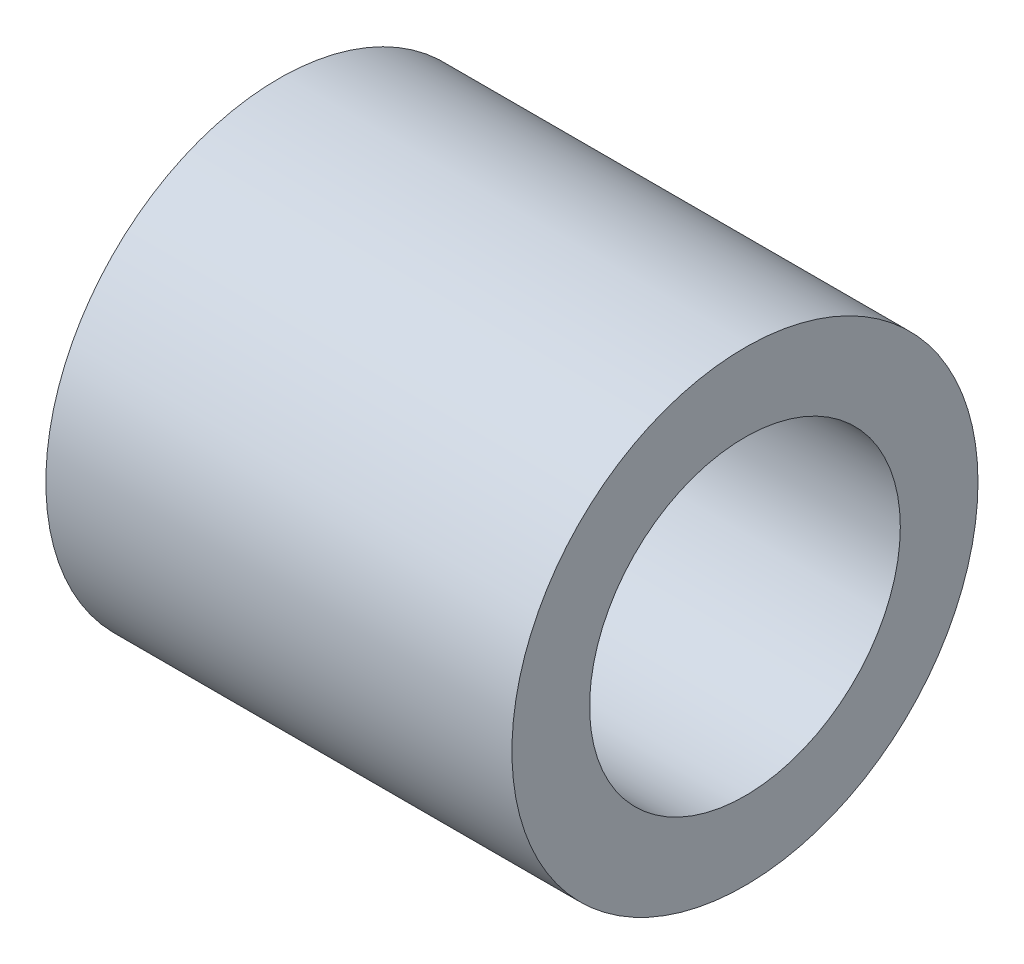
from build123d import *

# Parameters (mm, degrees)
SKETCH_1_R      = 9
SKETCH_1_R_2    = 6
EXTRUDE_1_DEPTH = 18


with BuildPart() as part:
    # 草图1 → 凸台-拉伸1 (new body)
    with BuildSketch(Plane(origin=(0, 0, 0), x_dir=(0, 0, -1), z_dir=(1, 0, 0))):
        Circle(SKETCH_1_R)
        Circle(SKETCH_1_R_2, mode=Mode.SUBTRACT)
    extrude(amount=-EXTRUDE_1_DEPTH)


solid = part.part
